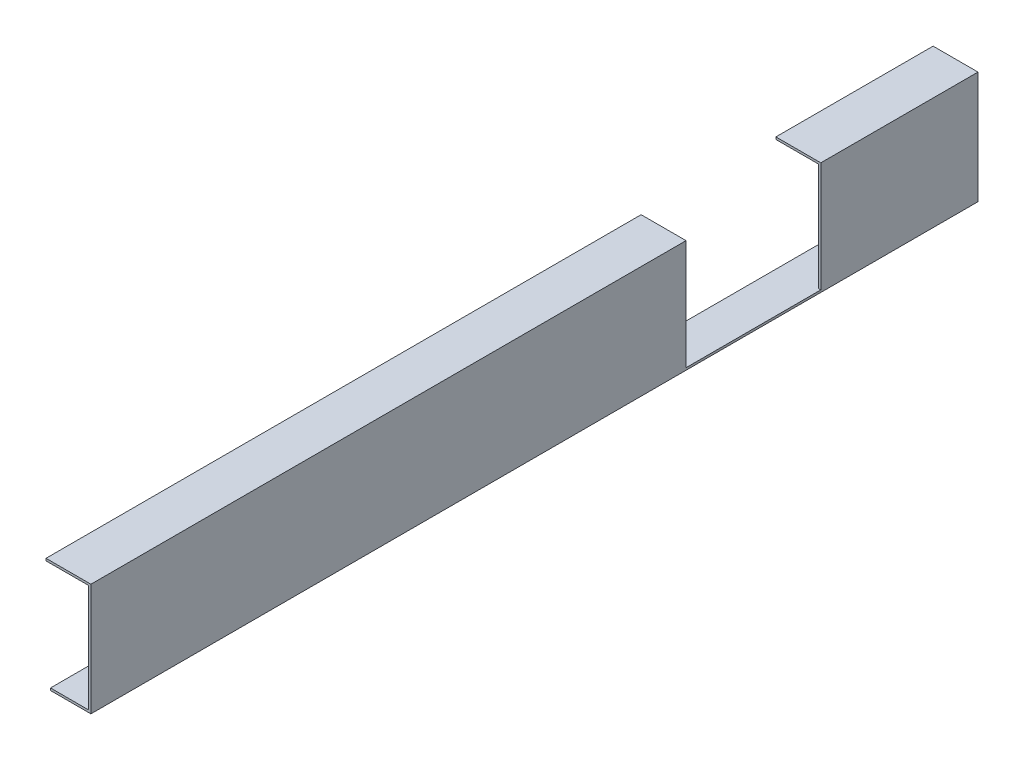
from build123d import *

# Parameters (mm, degrees)
BOSS_EXTRUDE1_DEPTH = 790
SKETCH2_W           = 120
SKETCH2_H           = 98
CUT_EXTRUDE1_DEPTH  = 224


with BuildPart() as part:
    # Sketch1 → Boss-Extrude1 (new body)
    with BuildSketch(Plane.XY):
        Polygon((-4, 46.666666667), (36, 46.666666667), (36, -53.333333333), (0, -53.333333333), (0, -51.333333333), (34, -51.333333333), (34, 44.666666667), (-4, 44.666666667), align=None)
    extrude(amount=BOSS_EXTRUDE1_DEPTH)

    # Sketch2 → Cut-Extrude1 (cut)
    with BuildSketch(Plane(origin=(36, 0, 0), x_dir=(0, 0, -1), z_dir=(1, 0, 0))):
        with Locations((-200, -2.333333333)):
            Rectangle(SKETCH2_W, SKETCH2_H)
    extrude(amount=-CUT_EXTRUDE1_DEPTH, mode=Mode.SUBTRACT)


solid = part.part
